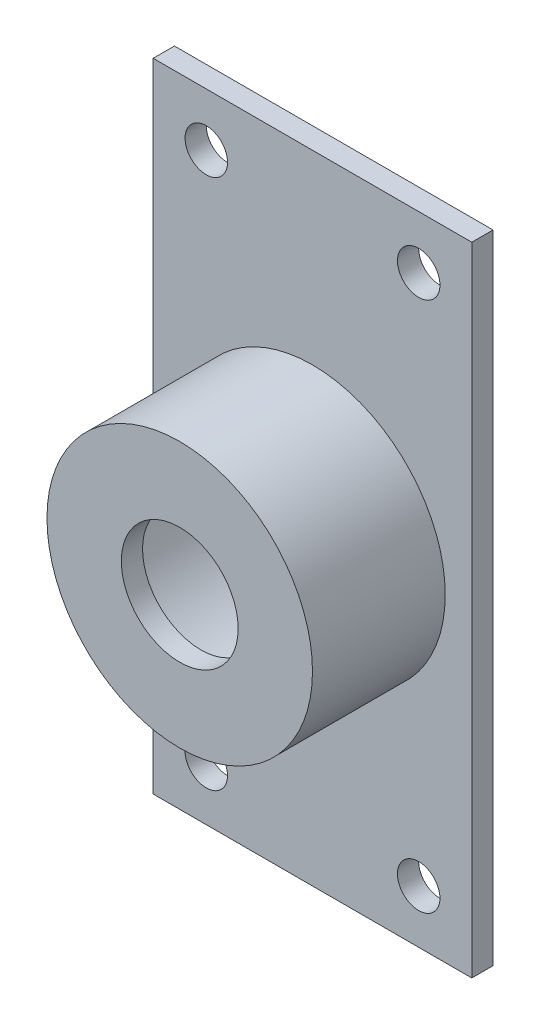
from build123d import *

# Parameters (mm, degrees)
SKETCH1_W           = 60
SKETCH1_H           = 120
BOSS_EXTRUDE1_DEPTH = 4
SKETCH2_R           = 4
CUT_EXTRUDE1_DEPTH  = 4
SKETCH3_R           = 25
BOSS_EXTRUDE2_DEPTH = 25
SKETCH4_R           = 21.6
CUT_EXTRUDE2_DEPTH  = 25
SKETCH5_R           = 11
CUT_EXTRUDE3_DEPTH  = 25


with BuildPart() as part:
    # Sketch1 → Boss-Extrude1 (new body)
    with BuildSketch(Plane.XY):
        Rectangle(SKETCH1_W, SKETCH1_H)
    extrude(amount=BOSS_EXTRUDE1_DEPTH)

    # Sketch2 → Cut-Extrude1 (cut)
    with BuildSketch(Plane.XY.offset(4)):
        with Locations((-20, 50)):
            Circle(SKETCH2_R)
        with Locations((20, 50)):
            Circle(SKETCH2_R)
        with Locations((20, -50)):
            Circle(SKETCH2_R)
        with Locations((-20, -50)):
            Circle(SKETCH2_R)
    extrude(amount=-CUT_EXTRUDE1_DEPTH, mode=Mode.SUBTRACT)

    # Sketch3 → Boss-Extrude2 (add)
    with BuildSketch(Plane.XY.offset(4)):
        Circle(SKETCH3_R)
    extrude(amount=BOSS_EXTRUDE2_DEPTH)

    # Sketch4 → Cut-Extrude2 (cut)
    with BuildSketch(Plane(origin=(0, 0, 0), x_dir=(-1, 0, 0), z_dir=(0, 0, -1))):
        Circle(SKETCH4_R)
    extrude(amount=-CUT_EXTRUDE2_DEPTH, mode=Mode.SUBTRACT)

    # Sketch5 → Cut-Extrude3 (cut)
    with BuildSketch(Plane.XY.offset(29)):
        Circle(SKETCH5_R)
    extrude(amount=-CUT_EXTRUDE3_DEPTH, mode=Mode.SUBTRACT)


solid = part.part
